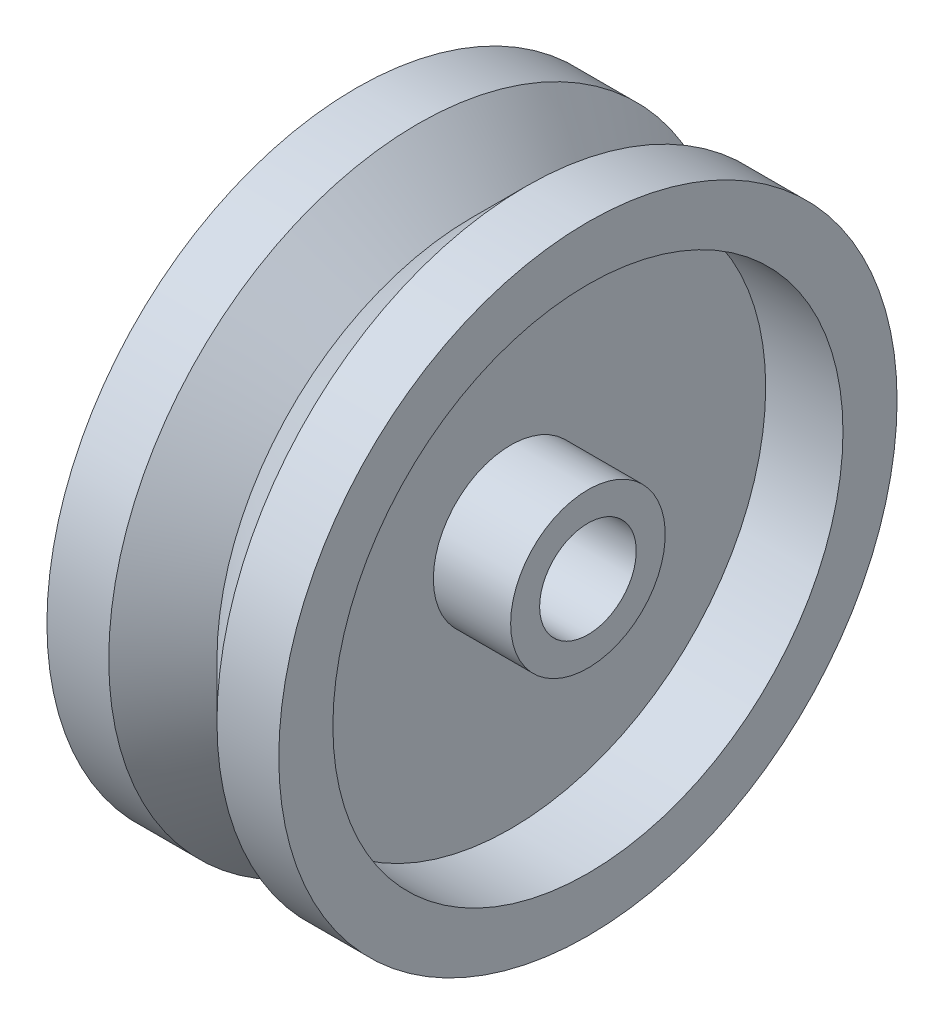
from build123d import *


with BuildPart() as part:
    # Sketch1 → Revolve1 (revolve)
    with BuildSketch(Plane.XY):
        Polygon((-7.5, 3.125), (7.5, 3.125), (7.5, 5), (2.5, 5), (2.5, 16.5), (7.5, 16.5), (7.5, 20), (3.5, 20), (0, 16.5), (-3.5, 20), (-7.5, 20), (-7.5, 16.5), (-2.5, 16.5), (-2.5, 5), (-7.5, 5), align=None)
    revolve(axis=Axis((-66.369289322, 0, 0), (1, 0, 0)))


solid = part.part
